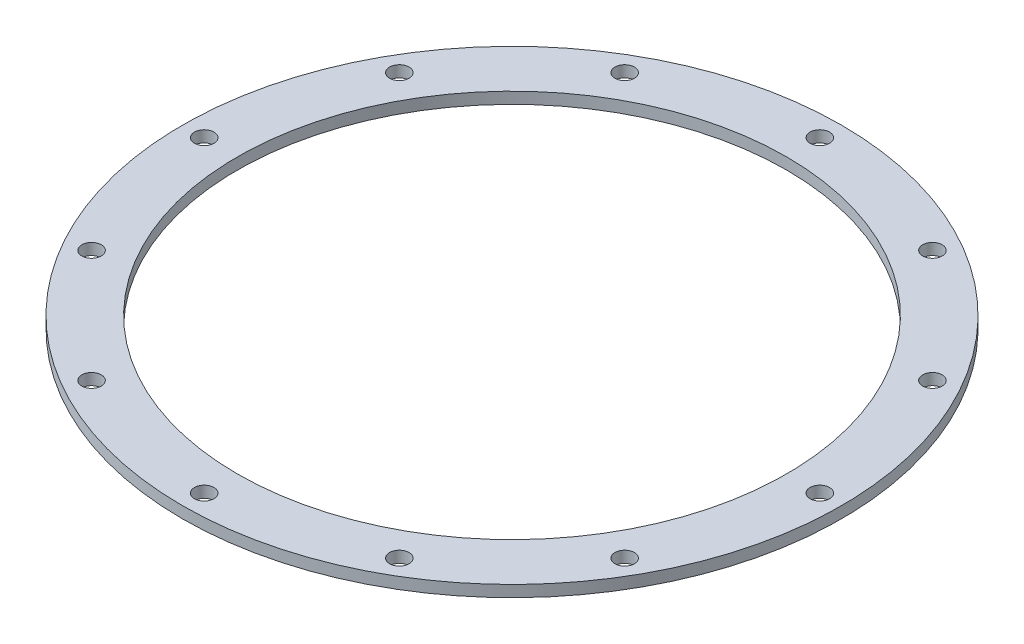
from build123d import *

# Parameters (mm, degrees)
SKETCH1_W                    = 7.62
SKETCH1_H                    = 1.5875
F_36_0_1065_DIAMETER_HOLE1_D = 2.7051
SCREW_PASSTHROUGHS_COUNT     = 12


with BuildPart() as part:
    # Sketch1 → Main (revolve)
    with BuildSketch(Plane.XY):
        with Locations((-41.91, 0.79375)):
            Rectangle(SKETCH1_W, SKETCH1_H)
    revolve(axis=Axis((0, 55, 0), (0, -1, 0)))

    # #36 (0.1065) Diameter Hole1 (through all)
    with Locations(Plane(origin=(0, 0, 0), x_dir=(-1, 0, 0), z_dir=(0, -1, 0))):
        with Locations((42.700575, 0)):
            f_36_0_1065_diameter_hole1 = Hole(F_36_0_1065_DIAMETER_HOLE1_D / 2)

    # Screw Passthroughs: #36 (0.1065) Diameter Hole1 ×12 about axis
    screw_passthroughs_axis = Axis((0, 0, 0), (0, 1, 0))
    for i in range(1, SCREW_PASSTHROUGHS_COUNT):
        add(f_36_0_1065_diameter_hole1.rotate(screw_passthroughs_axis, i * 360 / SCREW_PASSTHROUGHS_COUNT), mode=Mode.SUBTRACT)


solid = part.part
